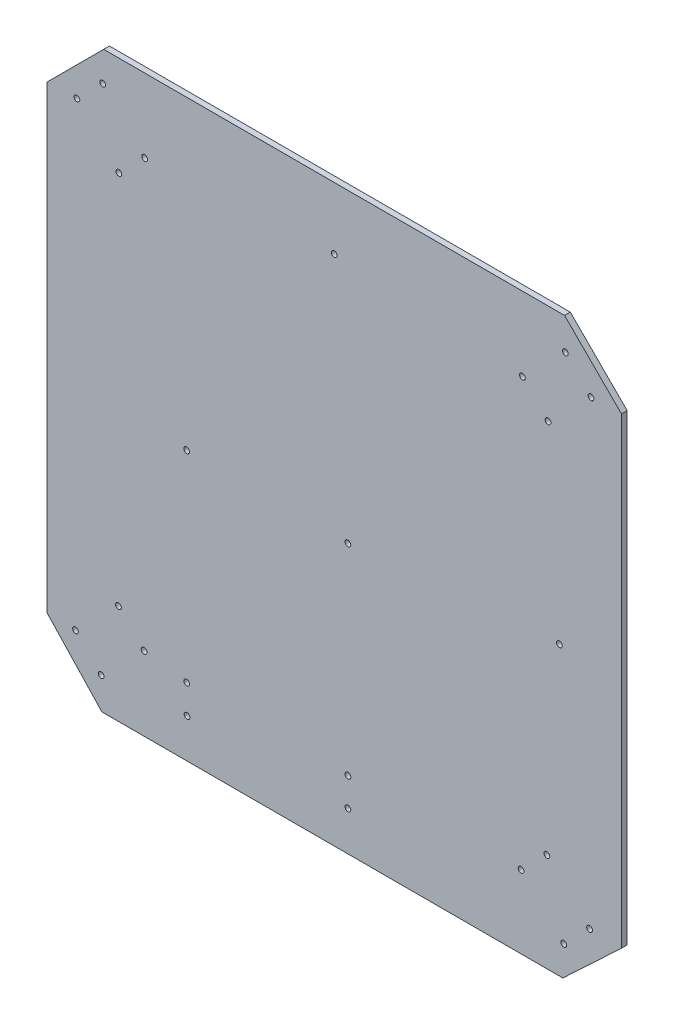
from build123d import *

# Parameters (mm, degrees)
SKETCH2_W           = 500
SKETCH2_H           = 500
BOSS_EXTRUDE1_DEPTH = 5
CUT_EXTRUDE1_DEPTH  = 5
SKETCH4_R           = 2.5
CUT_EXTRUDE4_DEPTH  = 354.588744165
SKETCH6_R           = 2.5
CUT_EXTRUDE5_DEPTH  = 354.588744165
SKETCH6_3_R         = 2.5
CUT_EXTRUDE6_DEPTH  = 354.588744165
SKETCH7_R           = 2.5
CUT_EXTRUDE7_DEPTH  = 354.588744165


with BuildPart() as part:
    # Sketch2 → Boss-Extrude1 (new body)
    with BuildSketch(Plane.XY):
        Rectangle(SKETCH2_W, SKETCH2_H)
    extrude(amount=BOSS_EXTRUDE1_DEPTH)

    # Sketch3 → Cut-Extrude1 (cut)
    with BuildSketch(Plane.XY.offset(5)):
        Polygon((-250, 250), (-250, 200.502525317), (-200.502525317, 250), align=None)
        Polygon((-202.085866883, -250), (-250, -198.968285864), (-250, -250), align=None)
        Polygon((250, 250), (200.502525317, 250), (250, 200.502525317), align=None)
        Polygon((250, -202.085866883), (198.968285864, -250), (250, -250), align=None)
    extrude(amount=-CUT_EXTRUDE1_DEPTH, mode=Mode.SUBTRACT)

    # Sketch4 → Cut-Extrude4 (cut, through all)
    with BuildSketch(Plane.XY.offset(5)):
        with Locations((-223.784016088, 201.333375785)):
            Circle(SKETCH4_R)
        with Locations((-201.333375785, 223.784016088)):
            Circle(SKETCH4_R)
        with Locations((186.127258156, 163.01508885)):
            Circle(SKETCH4_R)
        with Locations((163.81847093, 185.606691548)):
            Circle(SKETCH4_R)
        with Locations((201.196010764, 222.516316525)):
            Circle(SKETCH4_R)
        with Locations((223.504797991, 199.924713826)):
            Circle(SKETCH4_R)
        with Locations((222.253825998, -201.338953508)):
            Circle(SKETCH4_R)
        with Locations((199.804611485, -223.79101951)):
            Circle(SKETCH4_R)
        with Locations((162.657933466, -186.649059247)):
            Circle(SKETCH4_R)
        with Locations((185.10714798, -164.196993245)):
            Circle(SKETCH4_R)
        with Locations((-187.65988085, -163.046698367)):
            Circle(SKETCH4_R)
        with Locations((-165.349658973, -185.636884284)):
            Circle(SKETCH4_R)
        with Locations((-202.724854759, -222.548882874)):
            Circle(SKETCH4_R)
        with Locations((-225.035076637, -199.958696957)):
            Circle(SKETCH4_R)
        with Locations((-187.311960925, 163.528745219)):
            Circle(SKETCH4_R)
        with Locations((-164.861320622, 185.979385522)):
            Circle(SKETCH4_R)
    extrude(amount=-CUT_EXTRUDE4_DEPTH, mode=Mode.SUBTRACT)

    # Sketch6 → Cut-Extrude5 (cut, through all)
    with BuildSketch(Plane.XY.offset(5)):
        with Locations((-128, -216)):
            Circle(SKETCH6_R)
        with Locations((-128.2846398, -16)):
            Circle(SKETCH6_R)
        with Locations((-128.2846398, -191)):
            Circle(SKETCH6_R)
    extrude(amount=-CUT_EXTRUDE5_DEPTH, mode=Mode.SUBTRACT)

    # Sketch6_3 → Cut-Extrude6 (cut, through all)
    with BuildSketch(Plane.XY.offset(5)):
        with Locations((12, -215.71527189)):
            Circle(SKETCH6_3_R)
        with Locations((12, -191)):
            Circle(SKETCH6_3_R)
        with Locations((12, -16)):
            Circle(SKETCH6_3_R)
    extrude(amount=-CUT_EXTRUDE6_DEPTH, mode=Mode.SUBTRACT)

    # Sketch7 → Cut-Extrude7 (cut, through all)
    with BuildSketch(Plane.XY.offset(5)):
        with Locations((0, 196)):
            Circle(SKETCH7_R)
        with Locations((196, 0)):
            Circle(SKETCH7_R)
    extrude(amount=-CUT_EXTRUDE7_DEPTH, mode=Mode.SUBTRACT)


solid = part.part
